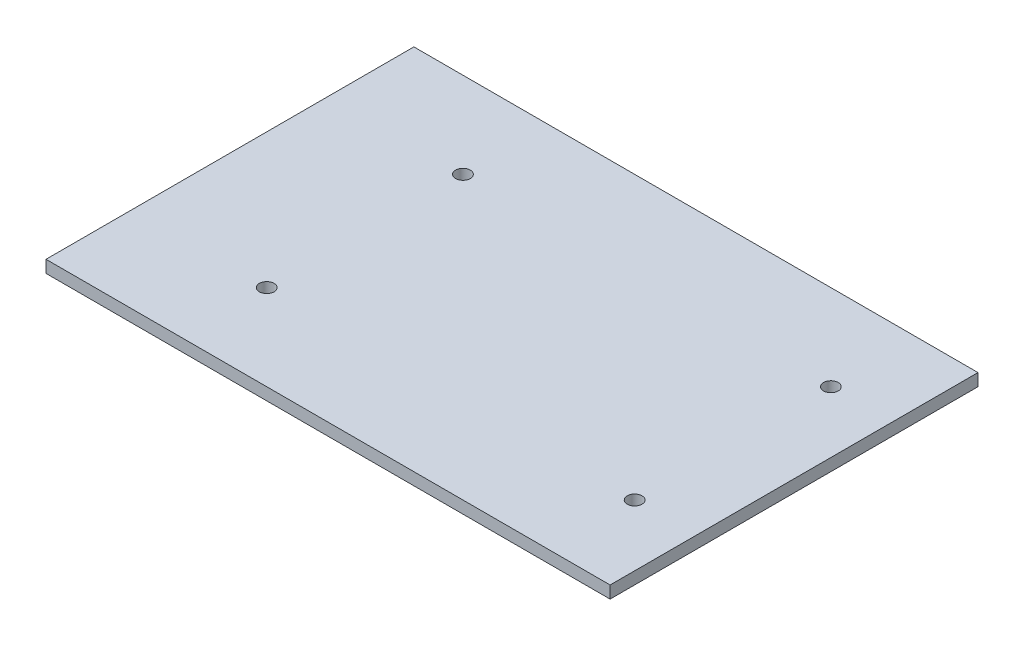
from build123d import *

# Parameters (mm, degrees)
SKETCH1_W           = 230
SKETCH1_H           = 150
BOSS_EXTRUDE1_DEPTH = 5
SKETCH3_R           = 3
CUT_EXTRUDE2_DEPTH  = 6
SKETCH4_R           = 3
CUT_EXTRUDE3_DEPTH  = 10


with BuildPart() as part:
    # Sketch1 → Boss-Extrude1 (new body)
    with BuildSketch(Plane(origin=(0, 0, 0), x_dir=(1, 0, 0), z_dir=(0, 1, 0))):
        with Locations((115, 75)):
            Rectangle(SKETCH1_W, SKETCH1_H)
    extrude(amount=BOSS_EXTRUDE1_DEPTH)

    # Sketch3 → Cut-Extrude2 (cut, through all)
    with BuildSketch(Plane(origin=(0, 5, 0), x_dir=(1, 0, 0), z_dir=(0, 1, 0))):
        with Locations((205, 35)):
            Circle(SKETCH3_R)
        with Locations((205, 115)):
            Circle(SKETCH3_R)
    extrude(amount=-CUT_EXTRUDE2_DEPTH, mode=Mode.SUBTRACT)

    # Sketch4 → Cut-Extrude3 (cut)
    with BuildSketch(Plane(origin=(0, 5, 0), x_dir=(1, 0, 0), z_dir=(0, 1, 0))):
        with Locations((55, 115)):
            Circle(SKETCH4_R)
        with Locations((55, 35)):
            Circle(SKETCH4_R)
    extrude(amount=-CUT_EXTRUDE3_DEPTH, mode=Mode.SUBTRACT)


solid = part.part
